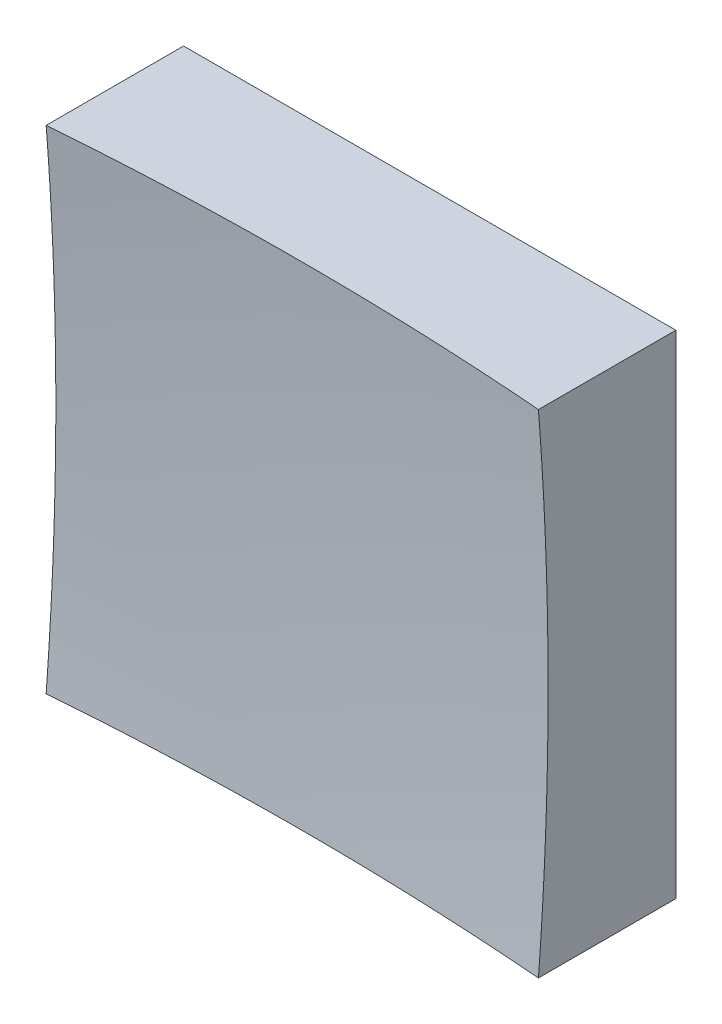
from build123d import *

# Parameters (mm, degrees)
SKETCH_1_W      = 12.5
SKETCH_1_H      = 12.5
EXTRUDE_1_DEPTH = 10


with BuildPart() as part:
    # 草图1 → 凸台-拉伸1 (new body)
    with BuildSketch(Plane.XY):
        Rectangle(SKETCH_1_W, SKETCH_1_H)
    extrude(amount=EXTRUDE_1_DEPTH)

    # 草图2 → 切除-旋转2 (revolve, cut)
    with BuildSketch(Plane(origin=(0, 0, 0), x_dir=(1, 0, 0), z_dir=(0, 1, 0))):
        with BuildLine():
            Line((77.987636945, -65.169450829), (0, -65.169450829))
            Line((0, -65.169450829), (0, -3))
            ThreePointArc((0, -3), (49.867605047, -20.444249131), (77.987636945, -65.169450829))
        make_face()
    revolve(axis=Axis((0, 0, 65.169450829), (0, 0, -1)), mode=Mode.SUBTRACT)


solid = part.part
